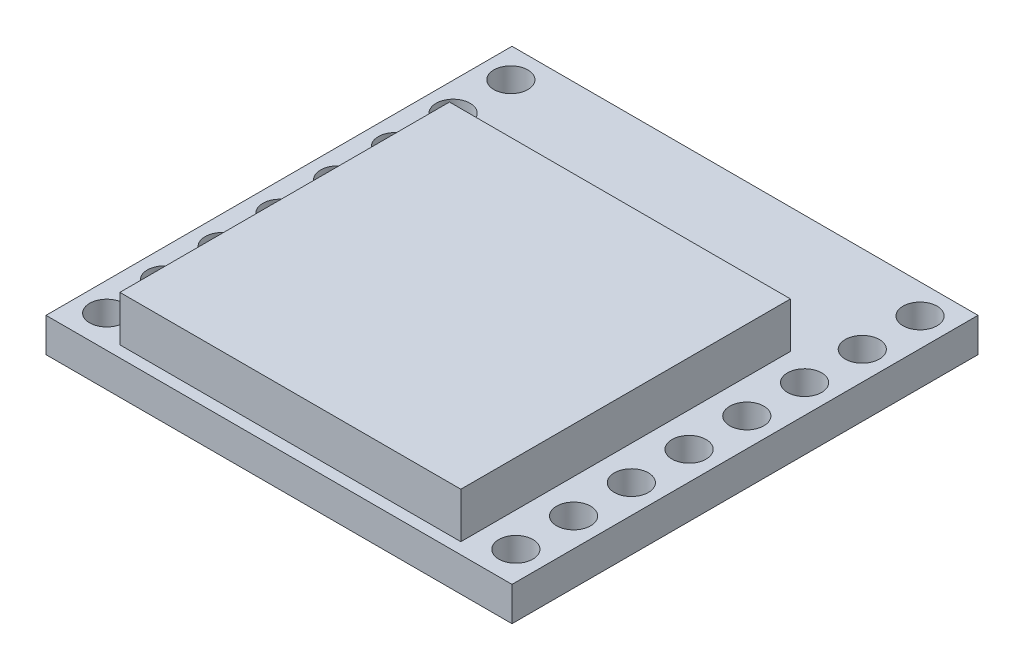
from build123d import *

# Parameters (mm, degrees)
SKETCH1_W           = 20.5
SKETCH1_H           = 20.5
BOSS_EXTRUDE1_DEPTH = 1.5
CUT_EXTRUDE1_START  = 1.5
SKETCH2_R           = 0.75
CUT_EXTRUDE1_DEPTH  = 2.5
BOSS_EXTRUDE2_START = 1.5
SKETCH3_W           = 15
SKETCH3_H           = 14.5
BOSS_EXTRUDE2_DEPTH = 2


with BuildPart() as part:
    # Sketch1 → Boss-Extrude1 (new body)
    with BuildSketch(Plane(origin=(0, 0, 0), x_dir=(1, 0, 0), z_dir=(0, 1, 0))):
        Rectangle(SKETCH1_W, SKETCH1_H)
    extrude(amount=BOSS_EXTRUDE1_DEPTH)

    # Sketch2 → Cut-Extrude1 (cut, through all)
    with BuildSketch(Plane(origin=(0, 0, 0), x_dir=(1, 0, 0), z_dir=(0, 1, 0)).offset(CUT_EXTRUDE1_START)):
        with Locations((-9, 8.95)):
            Circle(SKETCH2_R)
        with Locations((-9, 6.41)):
            Circle(SKETCH2_R)
        with Locations((-9, 3.87)):
            Circle(SKETCH2_R)
        with Locations((-9, 1.33)):
            Circle(SKETCH2_R)
        with Locations((-9, -1.21)):
            Circle(SKETCH2_R)
        with Locations((-9, -3.75)):
            Circle(SKETCH2_R)
        with Locations((-9, -6.29)):
            Circle(SKETCH2_R)
        with Locations((-9, -8.83)):
            Circle(SKETCH2_R)
        with Locations((9, -8.83)):
            Circle(SKETCH2_R)
        with Locations((9, -6.29)):
            Circle(SKETCH2_R)
        with Locations((9, -3.75)):
            Circle(SKETCH2_R)
        with Locations((9, -1.21)):
            Circle(SKETCH2_R)
        with Locations((9, 1.33)):
            Circle(SKETCH2_R)
        with Locations((9, 3.87)):
            Circle(SKETCH2_R)
        with Locations((9, 6.41)):
            Circle(SKETCH2_R)
        with Locations((9, 8.95)):
            Circle(SKETCH2_R)
    extrude(amount=-CUT_EXTRUDE1_DEPTH, mode=Mode.SUBTRACT)

    # Sketch3 → Boss-Extrude2 (add)
    with BuildSketch(Plane(origin=(0, 0, 0), x_dir=(1, 0, 0), z_dir=(0, 1, 0)).offset(BOSS_EXTRUDE2_START)):
        with Locations((0, -2.5)):
            Rectangle(SKETCH3_W, SKETCH3_H)
    extrude(amount=BOSS_EXTRUDE2_DEPTH)


solid = part.part
